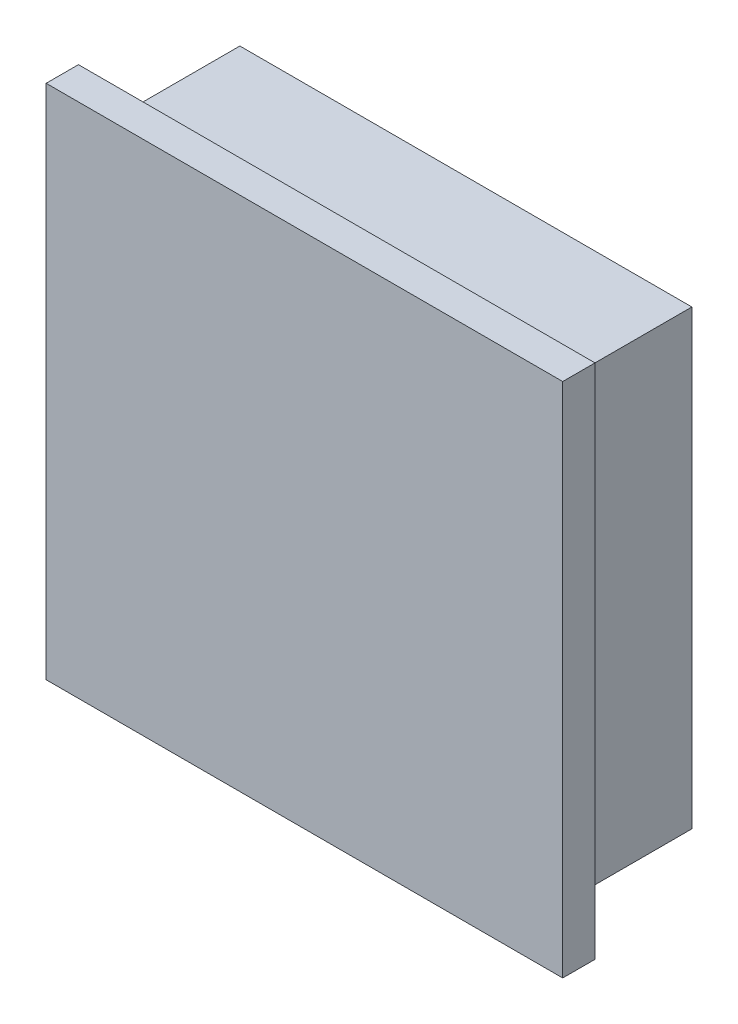
from build123d import *

# Parameters (mm, degrees)
SKETCH1_W           = 50.8
SKETCH1_H           = 50.8
BOSS_EXTRUDE1_DEPTH = 3.175
SKETCH1_4_W         = 44.45
SKETCH1_4_H         = 44.45
BOSS_EXTRUDE2_DEPTH = 12.7


with BuildPart() as part:
    # Sketch1 → Boss-Extrude1 (new body)
    with BuildSketch(Plane.XY):
        with Locations((22.225, 22.225)):
            Rectangle(SKETCH1_W, SKETCH1_H)
    extrude(amount=BOSS_EXTRUDE1_DEPTH)

    # Sketch1_4 → Boss-Extrude2 (add)
    with BuildSketch(Plane.XY):
        with Locations((22.225, 22.225)):
            Rectangle(SKETCH1_4_W, SKETCH1_4_H)
    extrude(amount=-BOSS_EXTRUDE2_DEPTH)


solid = part.part
